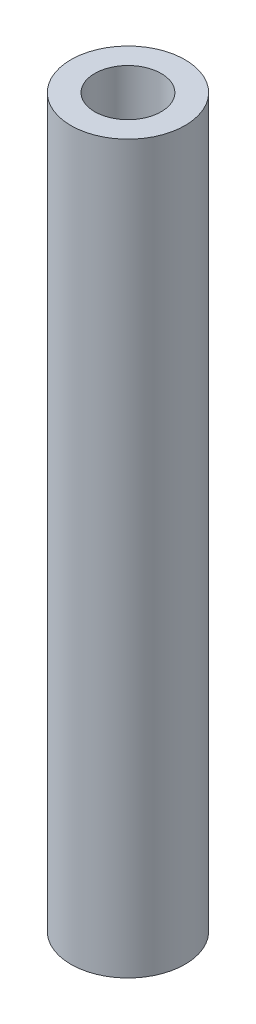
from build123d import *

# Parameters (mm, degrees)
SKETCH1_R           = 2.75
SKETCH1_R_2         = 1.6
BOSS_EXTRUDE1_DEPTH = 35


with BuildPart() as part:
    # Sketch1 → Boss-Extrude1 (new body)
    with BuildSketch(Plane(origin=(0, 0, 0), x_dir=(1, 0, 0), z_dir=(0, 1, 0))):
        Circle(SKETCH1_R)
        Circle(SKETCH1_R_2, mode=Mode.SUBTRACT)
    extrude(amount=BOSS_EXTRUDE1_DEPTH)


solid = part.part
